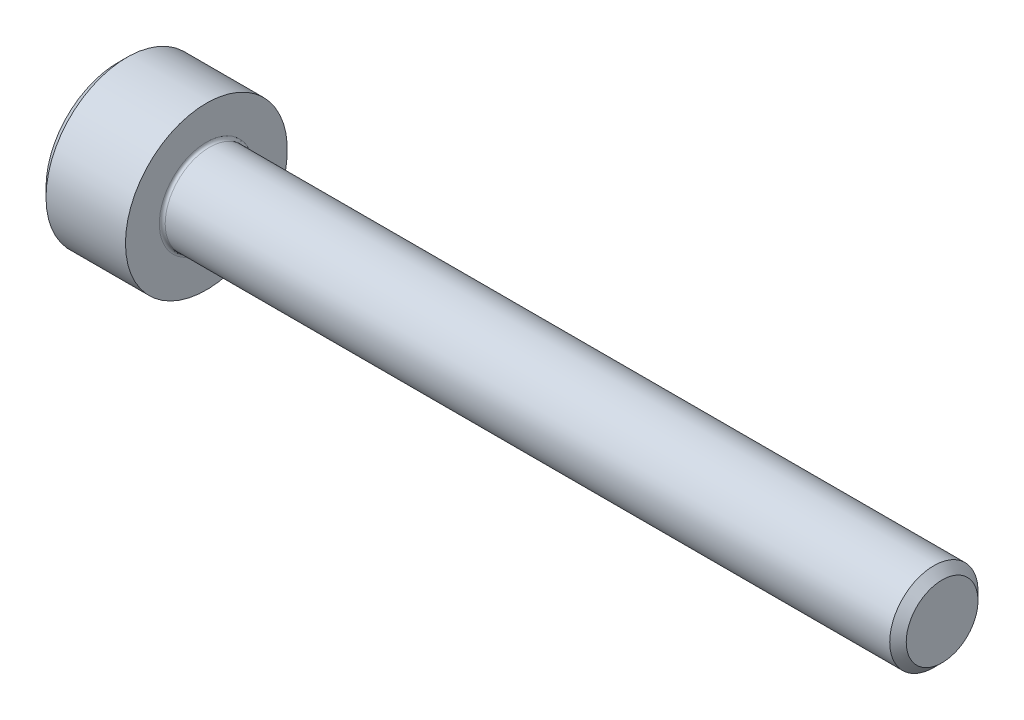
from build123d import *

# Parameters (mm, degrees)
FILLET1_R   = 0.1
HEX_2_DEPTH = 1.3


with BuildPart() as part:
    # BodySke → Base-Revolve (revolve)
    with BuildSketch(Plane.XY):
        Polygon((0, 0), (0, 2.45), (0.3, 2.75), (3, 2.75), (3, 1.5), (27.7195, 1.5), (28, 1.2195), (28, 0), align=None)
    revolve(axis=Axis((-31.75, 0, 0), (1, 0, 0)))

    # Fillet1
    fillet1_edges = [part.edges().sort_by_distance(p)[0] for p in [
        (3, -1.5, 0),
    ]]
    fillet(fillet1_edges, radius=FILLET1_R)

    # Sketch2 → Hex-PreBroach (revolve, cut)
    with BuildSketch(Plane.XY):
        Polygon((0, 1.28), (1.3, 1.28), (2.039008345, 0), (0, 0), align=None)
    revolve(axis=Axis((0, 0, 0), (1, 0, 0)), mode=Mode.SUBTRACT)

    # Sketch3 → Hex 2 (cut)
    with BuildSketch(Plane(origin=(0, 0, 0), x_dir=(0, 0.5, 0.866025404), z_dir=(-1, 0, 0))):
        Polygon((0.739008345, 1.28), (-0.739008345, 1.28), (-1.478016689, 0), (-0.739008345, -1.28), (0.739008345, -1.28), (1.478016689, 0), align=None)
    extrude(amount=-HEX_2_DEPTH, mode=Mode.SUBTRACT)


solid = part.part
